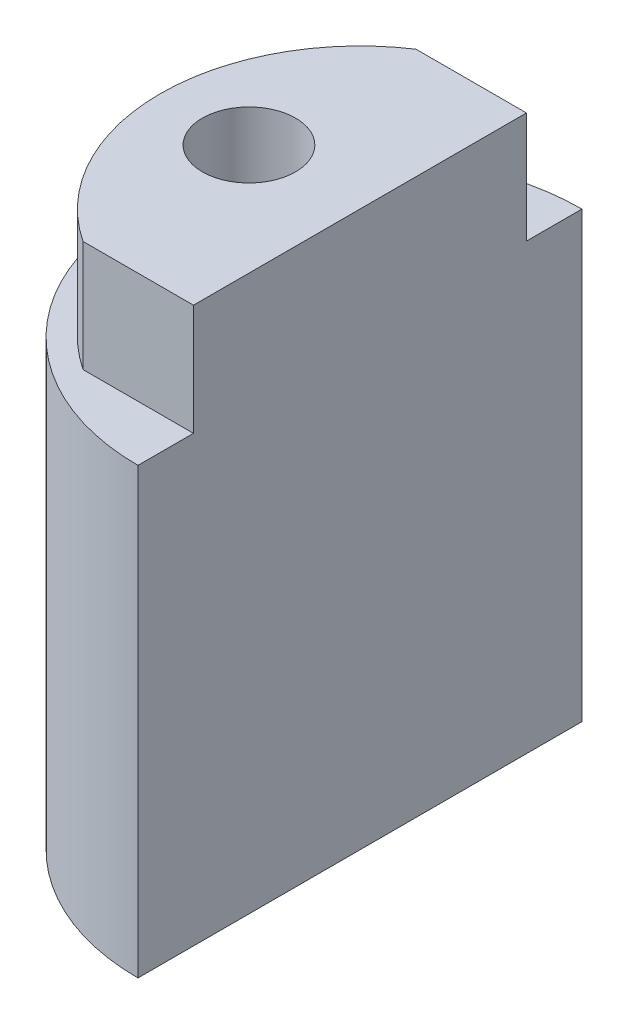
from build123d import *

# Parameters (mm, degrees)
BOSS_EXTRUDE1_DEPTH   = 25
CUT_EXTRUDE1_DEPTH    = 5
M5_TAPPED_HOLE1_D     = 4.2
M5_TAPPED_HOLE1_DEPTH = 11.1381927
M5_TAPPED_HOLE1_TIP   = 1.2618073


with BuildPart() as part:
    # Sketch1 → Boss-Extrude1 (new body)
    with BuildSketch(Plane(origin=(0, 0, 0), x_dir=(1, 0, 0), z_dir=(0, 1, 0))):
        with BuildLine():
            Line((0, 10), (0, -10))
            ThreePointArc((0, -10), (-10, 0), (0, 10))
        make_face()
    extrude(amount=BOSS_EXTRUDE1_DEPTH)

    # Sketch18 → Cut-Extrude1 (cut)
    with BuildSketch(Plane(origin=(0, 25, 0), x_dir=(1, 0, 0), z_dir=(0, 1, 0))):
        with BuildLine():
            Line((0, 7.5), (0, 10))
            ThreePointArc((0, 10), (-10, 0), (0, -10))
            Line((0, -10), (0, -7.5))
            Line((0, -7.5), (-4.974937186, -7.5))
            ThreePointArc((-4.974937186, -7.5), (-9, 0), (-4.974937186, 7.5))
            Line((-4.974937186, 7.5), (0, 7.5))
        make_face()
    extrude(amount=-CUT_EXTRUDE1_DEPTH, mode=Mode.SUBTRACT)

    # M5 Tapped Hole1
    with Locations(Plane(origin=(0, 25, 0), x_dir=(1, 0, 0), z_dir=(0, 1, 0))):
        with Locations((-5, 0)):
            Hole(M5_TAPPED_HOLE1_D / 2, depth=M5_TAPPED_HOLE1_DEPTH)
            with Locations((0, 0, -(M5_TAPPED_HOLE1_DEPTH + M5_TAPPED_HOLE1_TIP / 2))):  # 118° drill point
                Cone(0, M5_TAPPED_HOLE1_D / 2, M5_TAPPED_HOLE1_TIP, mode=Mode.SUBTRACT)


solid = part.part
